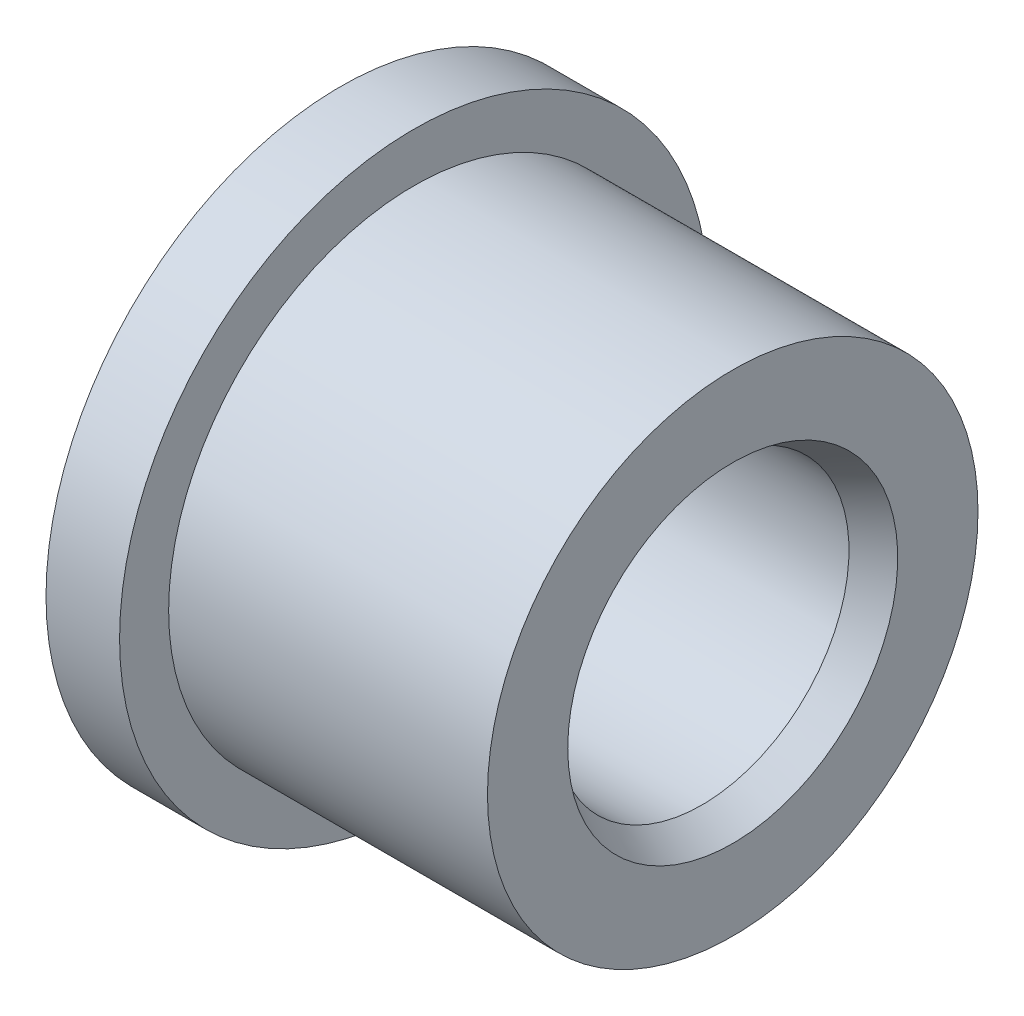
from build123d import *

# Parameters (mm, degrees)
CHAMFER1_SIZE         = 0.5
CHAMFER1_SIZE2        = 0.288675135
CHAMFER1_PART_2_SIZE  = 0.5
CHAMFER1_PART_2_SIZE2 = 0.288675135


with BuildPart() as part:
    # Sketch1 → Revolve1 (revolve)
    with BuildSketch(Plane.XY):
        Polygon((0, 2.38125), (0, 4.7625), (1.190625, 4.7625), (1.190625, 3.96875), (6.35, 3.96875), (6.35, 2.38125), align=None)
    revolve(axis=Axis((0, 0, 0), (1, 0, 0)))

    # Chamfer1
    chamfer1_edges = [part.edges().sort_by_distance(p)[0] for p in [
        (6.35, -2.38125, 0),
    ]]
    chamfer1_side = [part.faces().sort_by_distance(p)[0] for p in [
        (3.175, -2.38125, 0),
    ]]
    chamfer(chamfer1_edges, length=CHAMFER1_SIZE, length2=CHAMFER1_SIZE2, reference=chamfer1_side[0])

    # Chamfer1 part 2
    chamfer1_part_2_edges = [part.edges().sort_by_distance(p)[0] for p in [
        (0, -2.38125, 0),
    ]]
    chamfer1_part_2_side = [part.faces().sort_by_distance(p)[0] for p in [
        (0, -2.515953842, 0),
    ]]
    chamfer(chamfer1_part_2_edges, length=CHAMFER1_PART_2_SIZE, length2=CHAMFER1_PART_2_SIZE2, reference=chamfer1_part_2_side[0])


solid = part.part
